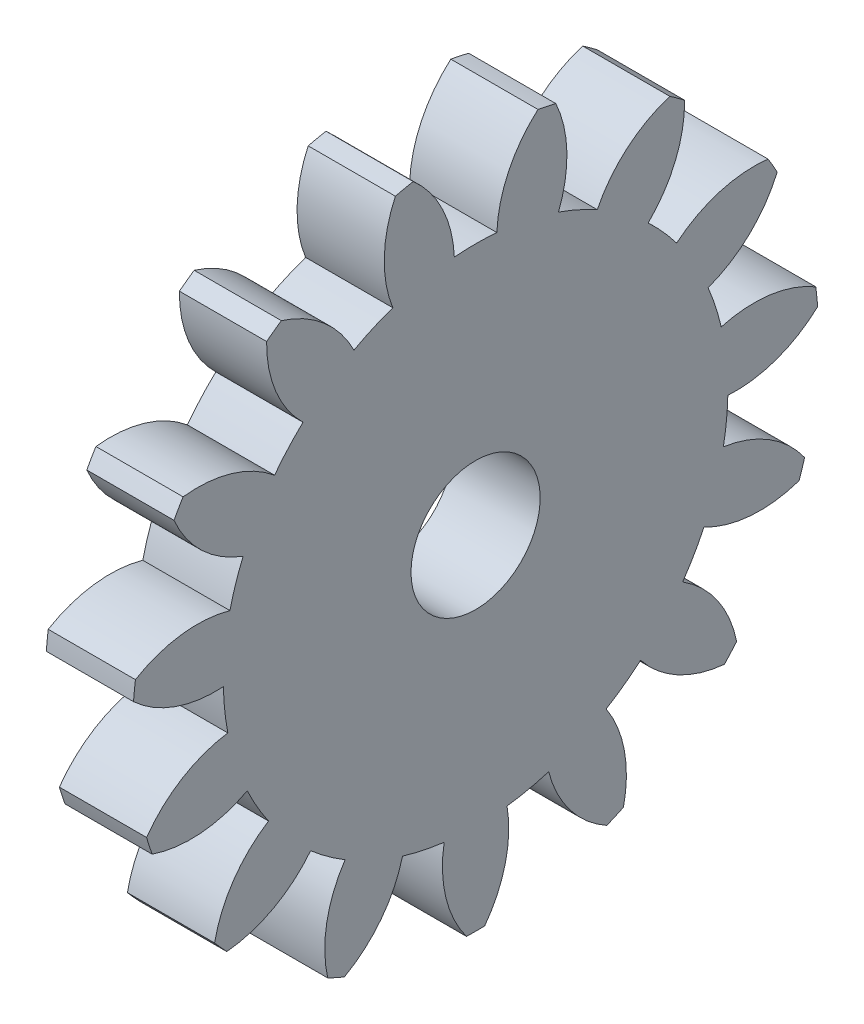
from build123d import *

# Parameters (mm, degrees)
BASPROSKE_W     = 5.4
BASPROSKE_H     = 21.25
TOOTHCUT_DEPTH  = 31.533342431
TEETHCUTS_COUNT = 15
TEETHCUTS_ANGLE = 336
BORSKE_R        = 4
BORE_DEPTH      = 50.0000508


with BuildPart() as part:
    # BasProSke → Base-Revolve (revolve)
    with BuildSketch(Plane(origin=(0, 0, 0), x_dir=(1, 0, 0), z_dir=(0, 1, 0)), mode=Mode.PRIVATE) as base_revolve_sk:
        with Locations((2.7, 10.625)):
            Rectangle(BASPROSKE_W, BASPROSKE_H)
    revolve(base_revolve_sk.sketch.rotate(Axis((-10, 0, 0), (1, 0, 0)), 180), axis=Axis((-10, 0, 0), (1, 0, 0)))

    # TooCutSke → ToothCut (cut, through all)
    with BuildSketch(Plane(origin=(0, 0, 0), x_dir=(0, 0, -1), z_dir=(1, 0, 0))):
        with BuildLine():
            ThreePointArc((1.317325472, 15.568366311), (0, 15.624), (-1.317325472, 15.568366311))
            ThreePointArc((-1.317325472, 15.568366311), (-2.05158513, 18.507838886), (-3.888921189, 20.916953343))
            ThreePointArc((-3.888921189, 20.916953343), (0, 21.2754), (3.888921189, 20.916953343))
            ThreePointArc((3.888921189, 20.916953343), (2.05158513, 18.507838886), (1.317325472, 15.568366311))
        make_face()
    toothcut = extrude(amount=TOOTHCUT_DEPTH, mode=Mode.SUBTRACT)

    # TeethCuts: ToothCut ×15 about axis
    teethcuts_axis = Axis((-10, 0, 0), (1, 0, 0))
    for i in range(1, TEETHCUTS_COUNT):
        add(toothcut.rotate(teethcuts_axis, i * TEETHCUTS_ANGLE / (TEETHCUTS_COUNT - 1)), mode=Mode.SUBTRACT)

    # BorSke → Bore (cut, symmetric)
    with BuildSketch(Plane(origin=(0, 0, 0), x_dir=(0, 0, -1), z_dir=(1, 0, 0))):
        with Locations(Location((0, 0, 0), (0, 0, 180))):
            Circle(BORSKE_R)
    extrude(amount=BORE_DEPTH, both=True, mode=Mode.SUBTRACT)


solid = part.part
